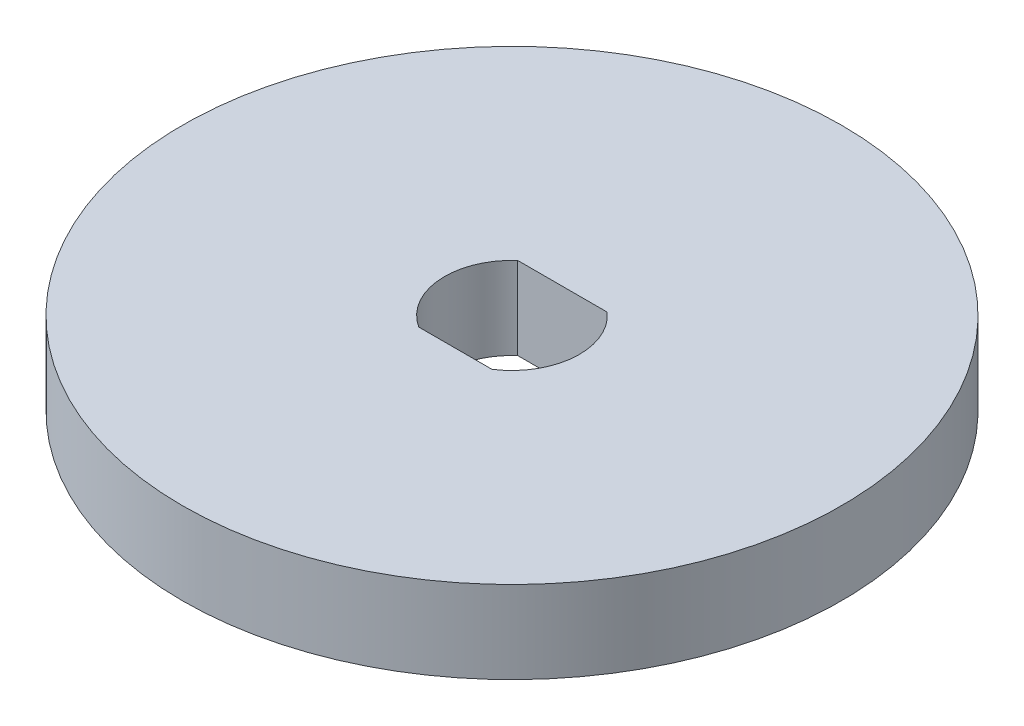
from build123d import *

# Parameters (mm, degrees)
SKETCH1_R           = 12.7
BOSS_EXTRUDE1_DEPTH = 3.175


with BuildPart() as part:
    # Sketch1 → Boss-Extrude1 (new body)
    with BuildSketch(Plane(origin=(0, 0, 0), x_dir=(1, 0, 0), z_dir=(0, 1, 0))):
        Circle(SKETCH1_R)
        with BuildLine():
            Line((-1.725, 1.945347013), (1.725, 1.945347013))
            ThreePointArc((1.725, 1.945347013), (2.592456696, -0.197909772), (1.409713207, -2.184652987))
            Line((1.409713207, -2.184652987), (-1.409713207, -2.184652987))
            ThreePointArc((-1.409713207, -2.184652987), (-2.592456696, -0.197909772), (-1.725, 1.945347013))
        make_face(mode=Mode.SUBTRACT)
    extrude(amount=BOSS_EXTRUDE1_DEPTH)


solid = part.part
